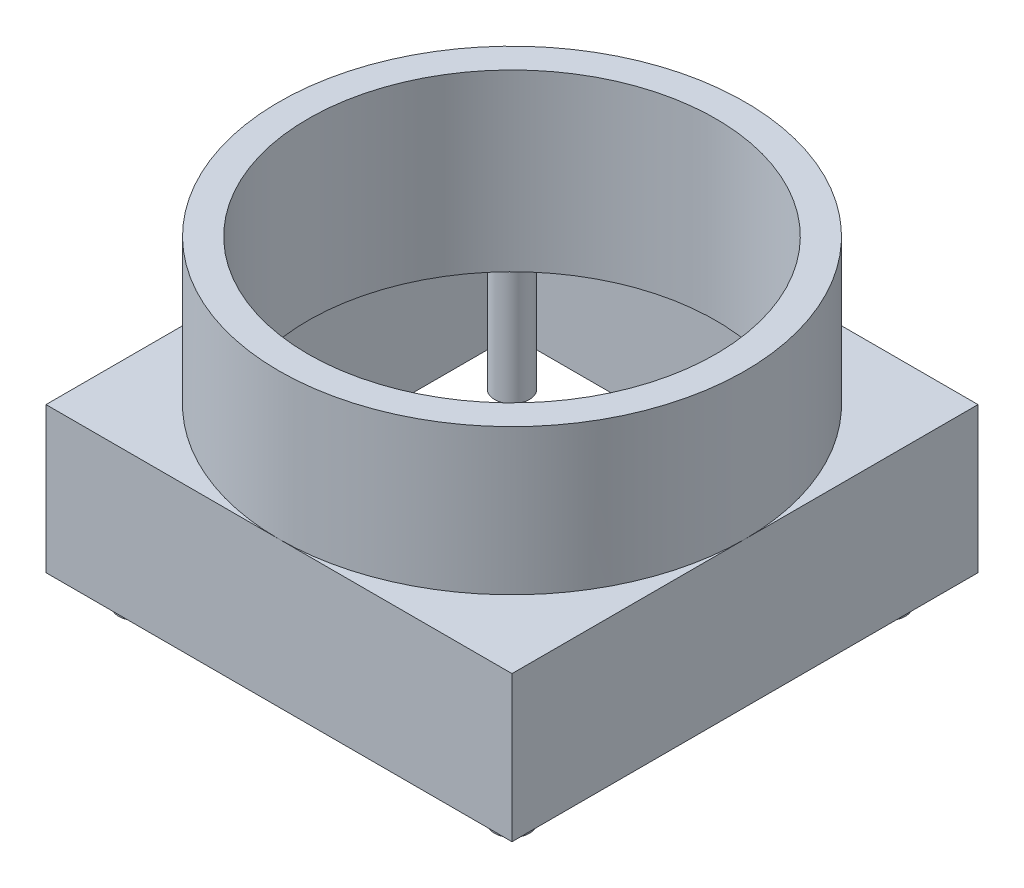
from build123d import *

# Parameters (mm, degrees)
SKETCH1_W             = 8
SKETCH1_H             = 8
SKETCH1_W_2           = 7.05
SKETCH1_H_2           = 7.05
BOSS_EXTRUDE1_DEPTH   = 2
SKETCH3_R             = 4
SKETCH3_R_2           = 3.5
BOSS_EXTRUDE3_DEPTH   = 3
BOSS_EXTRUDE4_DEPTH   = 0.5
SKETCH10_R            = 0.3
BOSS_EXTRUDE6_DEPTH   = 2.5
BOSS_EXTRUDE6_2_DEPTH = 2.5
BOSS_EXTRUDE6_3_DEPTH = 2.5
BOSS_EXTRUDE6_4_DEPTH = 2.5


with BuildPart() as part:
    # Sketch1 → Boss-Extrude1 (new body)
    with BuildSketch(Plane(origin=(0, 0, 0), x_dir=(1, 0, 0), z_dir=(0, 1, 0))):
        Rectangle(SKETCH1_W, SKETCH1_H)
        Rectangle(SKETCH1_W_2, SKETCH1_H_2, mode=Mode.SUBTRACT)
    extrude(amount=BOSS_EXTRUDE1_DEPTH)

    # Sketch3 → Boss-Extrude3 (add)
    with BuildSketch(Plane(origin=(0, 2, 0), x_dir=(1, 0, 0), z_dir=(0, 1, 0))):
        Circle(SKETCH3_R)
        Circle(SKETCH3_R_2, mode=Mode.SUBTRACT)
    extrude(amount=BOSS_EXTRUDE3_DEPTH)

    # Sketch5 → Boss-Extrude4 (add)
    with BuildSketch(Plane(origin=(0, 2, 0), x_dir=(1, 0, 0), z_dir=(0, 1, 0))):
        with BuildLine():
            Line((4, 4), (0, 4))
            ThreePointArc((0, 4), (0.974679434, 3.879432948), (1.890601756, 3.525))
            Line((1.890601756, 3.525), (3.525, 3.525))
            Line((3.525, 3.525), (3.525, 1.890601756))
            ThreePointArc((3.525, 1.890601756), (3.879432948, 0.974679434), (4, 0))
            Line((4, 0), (4, 4))
        make_face()
        with BuildLine():
            Line((4, -4), (4, 0))
            ThreePointArc((4, 0), (3.879432948, -0.974679434), (3.525, -1.890601756))
            Line((3.525, -1.890601756), (3.525, -3.525))
            Line((3.525, -3.525), (1.890601756, -3.525))
            ThreePointArc((1.890601756, -3.525), (0.974679434, -3.879432948), (0, -4))
            Line((0, -4), (4, -4))
        make_face()
        with BuildLine():
            Line((-3.525, -3.525), (-3.525, -1.890601756))
            ThreePointArc((-3.525, -1.890601756), (-3.879432948, -0.974679434), (-4, 0))
            Line((-4, 0), (-4, -4))
            Line((-4, -4), (0, -4))
            ThreePointArc((0, -4), (-0.974679434, -3.879432948), (-1.890601756, -3.525))
            Line((-1.890601756, -3.525), (-3.525, -3.525))
        make_face()
        with BuildLine():
            ThreePointArc((-1.890601756, 3.525), (-0.974679434, 3.879432948), (0, 4))
            Line((0, 4), (-4, 4))
            Line((-4, 4), (-4, 0))
            ThreePointArc((-4, 0), (-3.879432948, 0.974679434), (-3.525, 1.890601756))
            Line((-3.525, 1.890601756), (-3.525, 3.525))
            Line((-3.525, 3.525), (-1.890601756, 3.525))
        make_face()
        with BuildLine():
            ThreePointArc((-3.525, 1.890601756), (-2.828427125, 2.828427125), (-1.890601756, 3.525))
            Line((-1.890601756, 3.525), (-3.525, 3.525))
            Line((-3.525, 3.525), (-3.525, 1.890601756))
        make_face()
        with BuildLine():
            ThreePointArc((-1.890601756, -3.525), (-2.828427125, -2.828427125), (-3.525, -1.890601756))
            Line((-3.525, -1.890601756), (-3.525, -3.525))
            Line((-3.525, -3.525), (-1.890601756, -3.525))
        make_face()
        with BuildLine():
            Line((3.525, -3.525), (3.525, -1.890601756))
            ThreePointArc((3.525, -1.890601756), (2.828427125, -2.828427125), (1.890601756, -3.525))
            Line((1.890601756, -3.525), (3.525, -3.525))
        make_face()
        with BuildLine():
            Line((3.525, 3.525), (1.890601756, 3.525))
            ThreePointArc((1.890601756, 3.525), (2.828427125, 2.828427125), (3.525, 1.890601756))
            Line((3.525, 1.890601756), (3.525, 3.525))
        make_face()
    extrude(amount=BOSS_EXTRUDE4_DEPTH)


with BuildPart() as body_2:
    # Sketch10 → Boss-Extrude6 (new body)
    with BuildSketch(Plane.XZ.offset(-2)):
        with Locations((3.225, 3.225)):
            Circle(SKETCH10_R)
    extrude(amount=BOSS_EXTRUDE6_DEPTH)


with BuildPart() as body_3:
    # Sketch10 → Boss-Extrude6 2 (new body)
    with BuildSketch(Plane.XZ.offset(-2)):
        with Locations((3.225, -3.225)):
            Circle(SKETCH10_R)
    extrude(amount=BOSS_EXTRUDE6_2_DEPTH)


with BuildPart() as body_4:
    # Sketch10 → Boss-Extrude6 3 (new body)
    with BuildSketch(Plane.XZ.offset(-2)):
        with Locations((-3.225, -3.225)):
            Circle(SKETCH10_R)
    extrude(amount=BOSS_EXTRUDE6_3_DEPTH)


with BuildPart() as body_5:
    # Sketch10 → Boss-Extrude6 4 (new body)
    with BuildSketch(Plane.XZ.offset(-2)):
        with Locations((-3.225, 3.225)):
            Circle(SKETCH10_R)
    extrude(amount=BOSS_EXTRUDE6_4_DEPTH)


solid = Compound([part.part, body_2.part, body_3.part, body_4.part, body_5.part])
